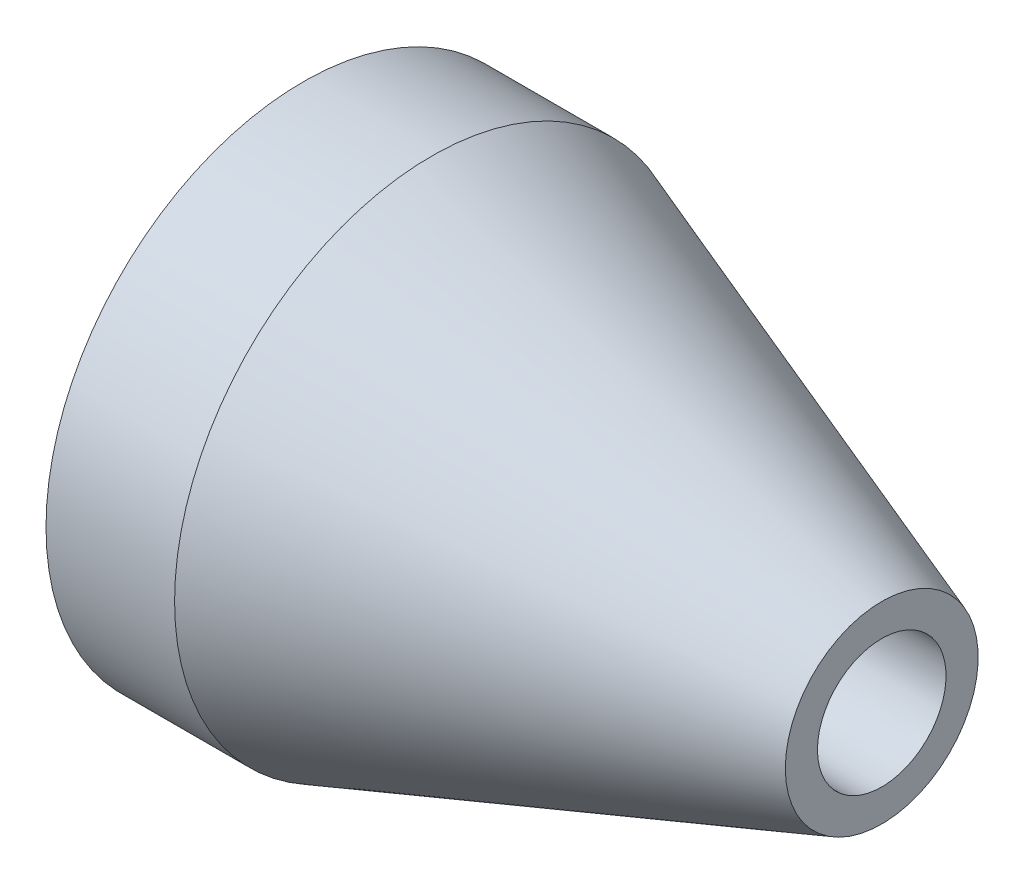
from build123d import *


with BuildPart() as part:
    # Sketch1 → Revolve1 (revolve)
    with BuildSketch(Plane.XY, mode=Mode.PRIVATE) as revolve1_sk:
        Polygon((0, -7.5), (0, -20), (10, -20), (45, -7.5), (45, -5), (0, -5), align=None)
    revolve(revolve1_sk.sketch.rotate(Axis((0, 0, 0), (1, 0, 0)), 270), axis=Axis((0, 0, 0), (1, 0, 0)))  # turned: the seam where the file's is


solid = part.part
